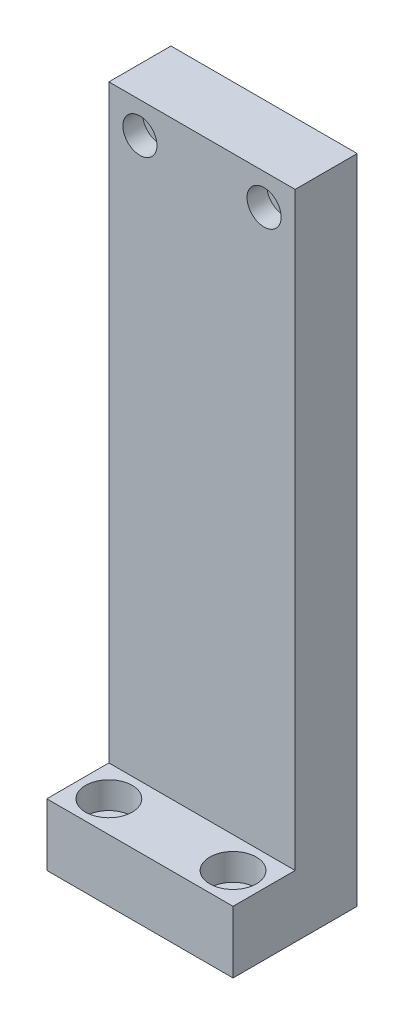
from build123d import *

# Parameters (mm, degrees)
SKETCH_2_W                   = 60
SKETCH_2_H                   = 210
EXTRUDE_1_DEPTH              = 40
SKETCH_3_W                   = 60
SKETCH_3_H                   = 190
CUT_EXTRUDE_1_DEPTH          = 20
HOLE_WIZARD_M6_2_D           = 6.4
HOLE_WIZARD_M6_2_CBORE_D     = 11
HOLE_WIZARD_M6_2_CBORE_DEPTH = 6.4
HOLE_WIZARD_M8_2_D           = 8.4
HOLE_WIZARD_M8_2_CBORE_D     = 15
HOLE_WIZARD_M8_2_CBORE_DEPTH = 8.6


with BuildPart() as part:
    # 草图2 → 凸台-拉伸1 (new body)
    with BuildSketch(Plane.XY):
        Rectangle(SKETCH_2_W, SKETCH_2_H)
    extrude(amount=EXTRUDE_1_DEPTH)

    # 草图3 → 切除-拉伸1 (cut)
    with BuildSketch(Plane.XY.offset(40)):
        with Locations((0, 10)):
            Rectangle(SKETCH_3_W, SKETCH_3_H)
    extrude(amount=-CUT_EXTRUDE_1_DEPTH, mode=Mode.SUBTRACT)

    # M6 六角凹头螺钉的柱形沉头孔2 (through all)
    with Locations(Plane(origin=(-20, 95, 20), x_dir=(1, 0, 0), z_dir=(0, 0, 1))):
        with Locations((0, 0), (40, 0)):
            CounterBoreHole(HOLE_WIZARD_M6_2_D / 2, HOLE_WIZARD_M6_2_CBORE_D / 2, HOLE_WIZARD_M6_2_CBORE_DEPTH)

    # M8 六角凹头螺钉的柱形沉头孔2 (through all)
    with Locations(Plane(origin=(-20, -85, 30), x_dir=(0, 0, 1), z_dir=(0, 1, 0))):
        with Locations((0, 0), (0, 40)):
            CounterBoreHole(HOLE_WIZARD_M8_2_D / 2, HOLE_WIZARD_M8_2_CBORE_D / 2, HOLE_WIZARD_M8_2_CBORE_DEPTH)


solid = part.part
